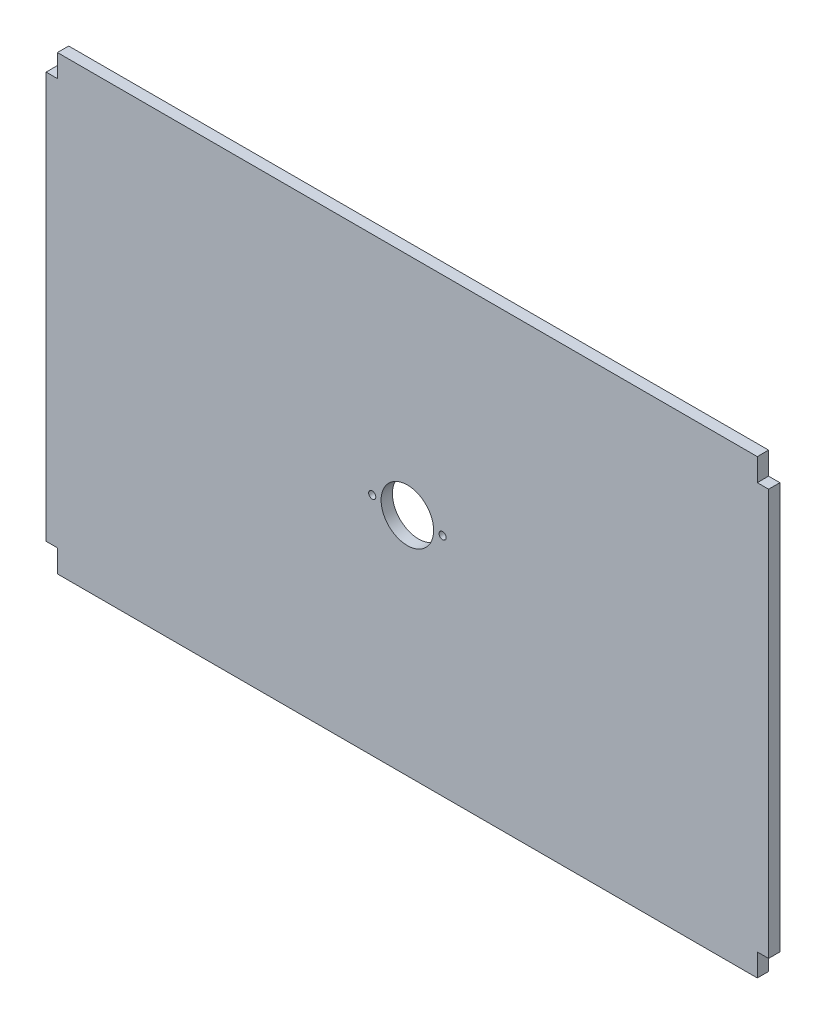
from build123d import *

# Parameters (mm, degrees)
BOSS_EXTRUDE1_DEPTH = 3.175
SKETCH3_R           = 7.39
SKETCH3_R_2         = 1
CUT_EXTRUDE1_DEPTH  = 4.175


with BuildPart() as part:
    # Sketch2 → Boss-Extrude1 (new body)
    with BuildSketch(Plane.XY):
        Polygon((0, 120.65), (0, 127), (196.85, 127), (196.85, 120.65), (200.025, 120.65), (200.025, 6.35), (196.85, 6.35), (196.85, 0), (0, 0), (0, 6.35), (-3.175, 6.35), (-3.175, 120.65), align=None)
    extrude(amount=BOSS_EXTRUDE1_DEPTH)

    # Sketch3 → Cut-Extrude1 (cut, through all)
    with BuildSketch(Plane.XY.offset(3.175)):
        with Locations((98.425, 63.5)):
            Circle(SKETCH3_R)
        with Locations((88.545, 63.5)):
            Circle(SKETCH3_R_2)
        with Locations((108.357, 63.5)):
            Circle(SKETCH3_R_2)
    extrude(amount=-CUT_EXTRUDE1_DEPTH, mode=Mode.SUBTRACT)


solid = part.part
